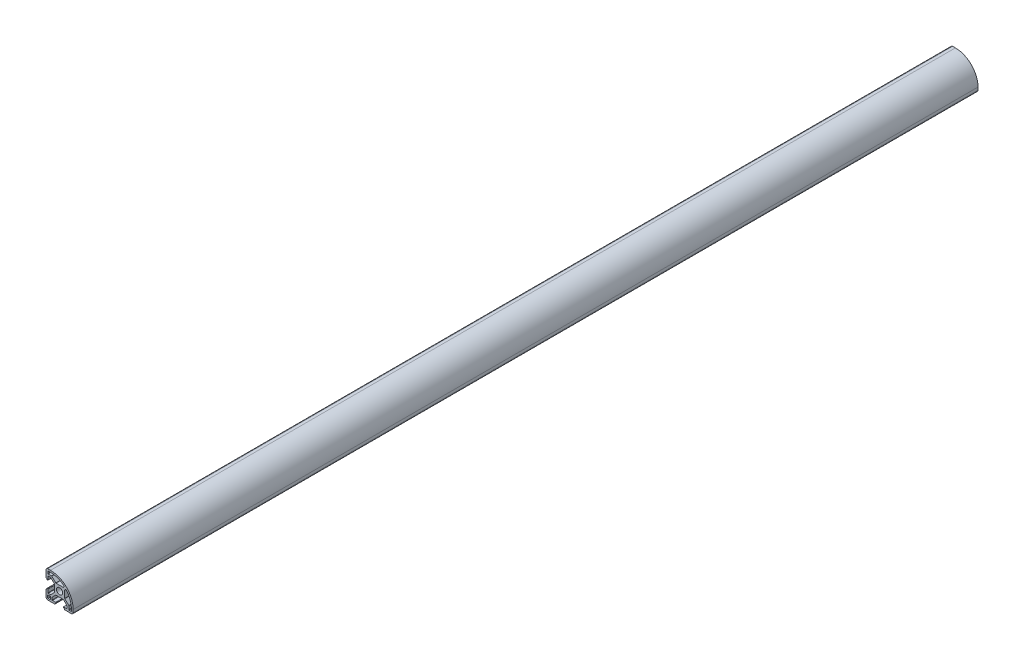
from build123d import *

# Parameters (mm, degrees)
SKETCH_1_R      = 3.4
EXTRUDE_1_DEPTH = 1000


with BuildPart() as part:
    # Эскиз1 → Бобышка-Вытянуть1 (new body)
    with BuildSketch(Plane.XY):
        with BuildLine():
            Line((-15, -5.5), (-15, -8.25))
            Line((-15, -8.25), (-15, -13))
            ThreePointArc((-15, -13), (-14.414213562, -14.414213562), (-13, -15))
            Line((-13, -15), (-8.25, -15))
            Line((-8.25, -15), (-5.5, -15))
            ThreePointArc((-5.5, -15), (-5.287867966, -14.912132034), (-5.2, -14.7))
            Line((-5.2, -14.7), (-5.2, -14))
            Line((-5.2, -14), (-4.4, -14))
            ThreePointArc((-4.4, -14), (-4.187867966, -13.912132034), (-4.1, -13.7))
            Line((-4.1, -13.7), (-4.1, -13.1))
            ThreePointArc((-4.1, -13.1), (-4.187867966, -12.887867966), (-4.4, -12.8))
            Line((-4.4, -12.8), (-7.95, -12.8))
            ThreePointArc((-7.95, -12.8), (-8.162132034, -12.712132034), (-8.25, -12.5))
            Line((-8.25, -12.5), (-8.25, -9.8))
            Line((-8.25, -9.8), (-4.25, -5.8))
            Line((-4.25, -5.8), (4.25, -5.8))
            Line((4.25, -5.8), (8.25, -9.8))
            Line((8.25, -9.8), (8.25, -12.5))
            ThreePointArc((8.25, -12.5), (8.162132034, -12.712132034), (7.95, -12.8))
            Line((7.95, -12.8), (4.4, -12.8))
            ThreePointArc((4.4, -12.8), (4.187867966, -12.887867966), (4.1, -13.1))
            Line((4.1, -13.1), (4.1, -13.7))
            ThreePointArc((4.1, -13.7), (4.187867966, -13.912132034), (4.4, -14))
            Line((4.4, -14), (5.2, -14))
            Line((5.2, -14), (5.2, -14.7))
            ThreePointArc((5.2, -14.7), (5.287867966, -14.912132034), (5.5, -15))
            Line((5.5, -15), (8.25, -15))
            Line((8.25, -15), (13, -15))
            ThreePointArc((13, -15), (14.414213562, -14.414213562), (15, -13))
            Line((15, -13), (15, -10))
            ThreePointArc((15, -10), (7.67766953, 7.67766953), (-10, 15))
            Line((-10, 15), (-13, 15))
            ThreePointArc((-13, 15), (-14.414213562, 14.414213562), (-15, 13))
            Line((-15, 13), (-15, 8.25))
            Line((-15, 8.25), (-15, 5.5))
            ThreePointArc((-15, 5.5), (-14.912132034, 5.287867966), (-14.7, 5.2))
            Line((-14.7, 5.2), (-14, 5.2))
            Line((-14, 5.2), (-14, 4.4))
            ThreePointArc((-14, 4.4), (-13.912132034, 4.187867966), (-13.7, 4.1))
            Line((-13.7, 4.1), (-13.1, 4.1))
            ThreePointArc((-13.1, 4.1), (-12.887867966, 4.187867966), (-12.8, 4.4))
            Line((-12.8, 4.4), (-12.8, 7.95))
            ThreePointArc((-12.8, 7.95), (-12.712132034, 8.162132034), (-12.5, 8.25))
            Line((-12.5, 8.25), (-9.8, 8.25))
            Line((-9.8, 8.25), (-5.8, 4.25))
            Line((-5.8, 4.25), (-5.8, -4.25))
            Line((-5.8, -4.25), (-9.8, -8.25))
            Line((-9.8, -8.25), (-12.5, -8.25))
            ThreePointArc((-12.5, -8.25), (-12.712132034, -8.162132034), (-12.8, -7.95))
            Line((-12.8, -7.95), (-12.8, -4.4))
            ThreePointArc((-12.8, -4.4), (-12.887867966, -4.187867966), (-13.1, -4.1))
            Line((-13.1, -4.1), (-13.7, -4.1))
            ThreePointArc((-13.7, -4.1), (-13.912132034, -4.187867966), (-14, -4.4))
            Line((-14, -4.4), (-14, -5.2))
            Line((-14, -5.2), (-14.7, -5.2))
            ThreePointArc((-14.7, -5.2), (-14.912132034, -5.287867966), (-15, -5.5))
        make_face()
        with BuildLine():
            ThreePointArc((-13.15, -10.35), (-13.003553391, -9.996446609), (-12.65, -9.85))
            Line((-12.65, -9.85), (-10.35, -9.85))
            ThreePointArc((-10.35, -9.85), (-9.996446609, -9.996446609), (-9.85, -10.35))
            Line((-9.85, -10.35), (-9.85, -12.65))
            ThreePointArc((-9.85, -12.65), (-9.996446609, -13.003553391), (-10.35, -13.15))
            Line((-10.35, -13.15), (-12.65, -13.15))
            ThreePointArc((-12.65, -13.15), (-13.003553391, -13.003553391), (-13.15, -12.65))
            Line((-13.15, -12.65), (-13.15, -10.35))
        make_face(mode=Mode.SUBTRACT)
        Circle(SKETCH_1_R, mode=Mode.SUBTRACT)
        with BuildLine():
            Line((13, -10), (13, -12.5))
            ThreePointArc((13, -12.5), (12.853553391, -12.853553391), (12.5, -13))
            Line((12.5, -13), (10.75, -13))
            ThreePointArc((10.75, -13), (10.396446609, -12.853553391), (10.25, -12.5))
            Line((10.25, -12.5), (10.25, -8.895836944))
            ThreePointArc((10.25, -8.895836944), (10.211939766, -8.704495228), (10.103553391, -8.542283553))
            Line((10.103553391, -8.542283553), (5.846446609, -4.285176772))
            ThreePointArc((5.846446609, -4.285176772), (5.738060234, -4.122965098), (5.7, -3.931623382))
            Line((5.7, -3.931623382), (5.7, 3.854163056))
            ThreePointArc((5.7, 3.854163056), (5.738060234, 4.045504772), (5.846446609, 4.207716447))
            Line((5.846446609, 4.207716447), (6.685973486, 5.047243323))
            ThreePointArc((6.685973486, 5.047243323), (7.057970063, 5.193349665), (7.418183029, 5.020216375))
            ThreePointArc((7.418183029, 5.020216375), (11.559431923, -1.988077936), (13, -10))
        make_face(mode=Mode.SUBTRACT)
        with BuildLine():
            Line((-13, 10.75), (-13, 12.5))
            ThreePointArc((-13, 12.5), (-12.853553391, 12.853553391), (-12.5, 13))
            Line((-12.5, 13), (-10, 13))
            ThreePointArc((-10, 13), (-1.988077936, 11.559431923), (5.020216375, 7.418183029))
            ThreePointArc((5.020216375, 7.418183029), (5.193349665, 7.057970063), (5.047243323, 6.685973486))
            Line((5.047243323, 6.685973486), (4.207716447, 5.846446609))
            ThreePointArc((4.207716447, 5.846446609), (4.045504772, 5.738060234), (3.854163056, 5.7))
            Line((3.854163056, 5.7), (-3.931623382, 5.7))
            ThreePointArc((-3.931623382, 5.7), (-4.122965098, 5.738060234), (-4.285176772, 5.846446609))
            Line((-4.285176772, 5.846446609), (-8.542283553, 10.103553391))
            ThreePointArc((-8.542283553, 10.103553391), (-8.704495228, 10.211939766), (-8.895836944, 10.25))
            Line((-8.895836944, 10.25), (-12.5, 10.25))
            ThreePointArc((-12.5, 10.25), (-12.853553391, 10.396446609), (-13, 10.75))
        make_face(mode=Mode.SUBTRACT)
    extrude(amount=EXTRUDE_1_DEPTH)


solid = part.part
